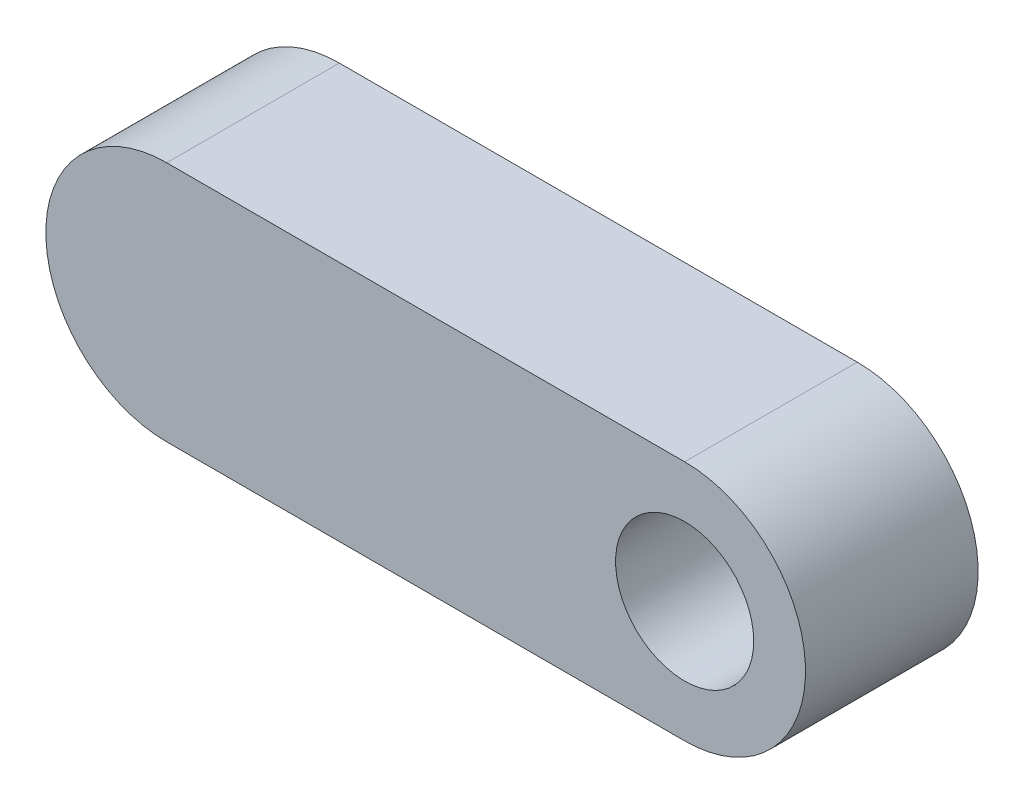
from build123d import *

# Parameters (mm, degrees)
DODANIE_WYCI_GNI_CIE1_DEPTH = 100
SZKIC2_R                    = 40
WYTNIJ_WYCI_GNI_CIE1_DEPTH  = 390.615194776


with BuildPart() as part:
    # Szkic1 → Dodanie-wyciągnięcie1 (new body)
    with BuildSketch(Plane.XY):
        with BuildLine():
            Line((0, 70), (300, 70))
            ThreePointArc((300, 70), (370, 0), (300, -70))
            Line((300, -70), (0, -70))
            ThreePointArc((0, -70), (-70, 0), (0, 70))
        make_face()
    extrude(amount=DODANIE_WYCI_GNI_CIE1_DEPTH)

    # Szkic2 → Wytnij-wyciągnięcie1 (cut, through all)
    with BuildSketch(Plane.XY.offset(100)):
        with Locations((300, 0)):
            Circle(SZKIC2_R)
    extrude(amount=-WYTNIJ_WYCI_GNI_CIE1_DEPTH, mode=Mode.SUBTRACT)


solid = part.part
